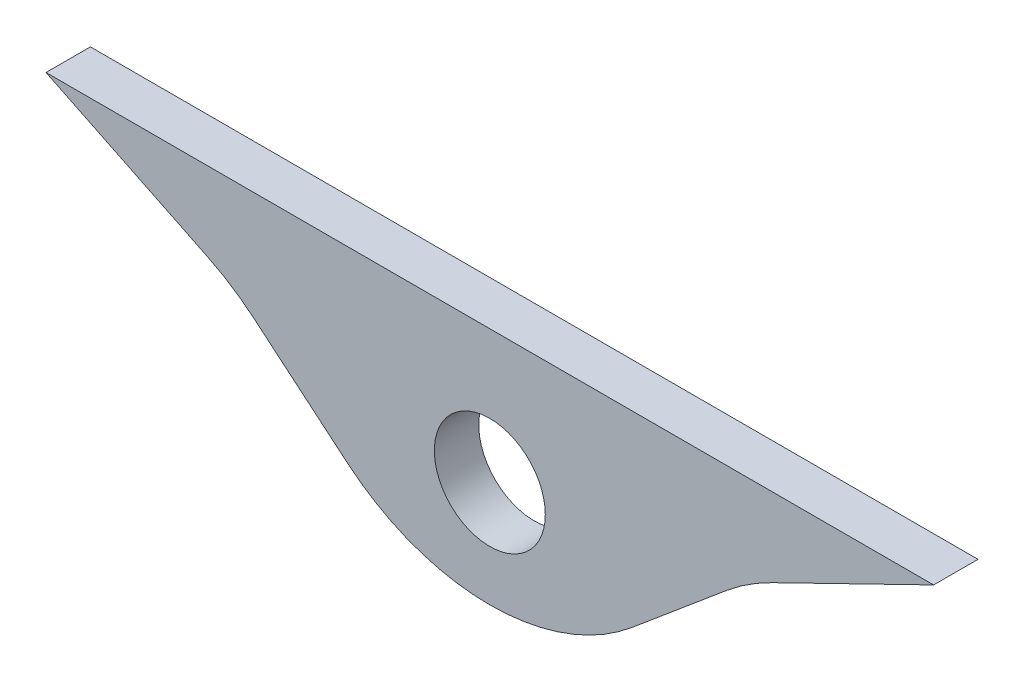
from build123d import *

# Parameters (mm, degrees)
SKETCH_1_R      = 2.5
EXTRUDE_1_DEPTH = 2
FILLET_1_R      = 10


with BuildPart() as part:
    # ｽｹｯﾁ1 → ﾎﾞｽ - 押し出し1 (new body)
    with BuildSketch(Plane.XY):
        Polygon((0, -7.832443736), (11.605504985, 1.905731217), (20, 6), (-20, 6), (-11.605504985, 1.905731217), align=None)
        Circle(SKETCH_1_R, mode=Mode.SUBTRACT)
    extrude(amount=EXTRUDE_1_DEPTH)

    # ﾌｨﾚｯﾄ1
    fillet_1_edges = [part.edges().sort_by_distance(p)[0] for p in [
        (-11.605504985, 1.905731217, 1),
        (11.605504985, 1.905731217, 1),
        (0, -7.832443736, 1),
    ]]
    fillet(fillet_1_edges, radius=FILLET_1_R)


solid = part.part
